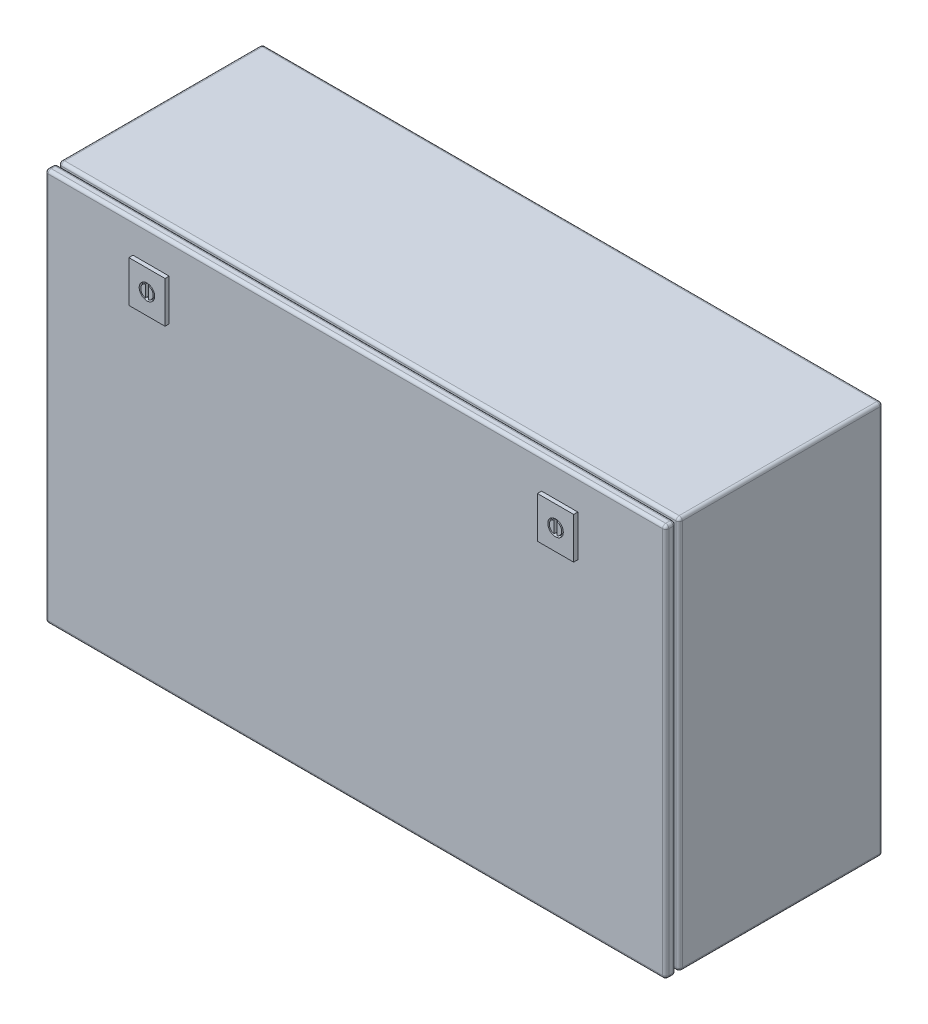
from build123d import *

# Parameters (mm, degrees)
SKETCH1_W           = 600
SKETCH1_H           = 380
BOSS_EXTRUDE1_DEPTH = 210
SKETCH2_W           = 600
SKETCH2_H           = 380
SKETCH2_W_2         = 580
SKETCH2_H_2         = 360
CUT_EXTRUDE3_DEPTH  = 3
FILLET3_R           = 3
SKETCH4_W           = 35
SKETCH4_H           = 40
BOSS_EXTRUDE3_DEPTH = 4
SKETCH5_R           = 7.5
CUT_EXTRUDE6_DEPTH  = 3


with BuildPart() as part:
    # Sketch1 → Boss-Extrude1 (new body)
    with BuildSketch(Plane.XY):
        with Locations((300, 190)):
            Rectangle(SKETCH1_W, SKETCH1_H)
    extrude(amount=BOSS_EXTRUDE1_DEPTH)

    # Sketch2 → Cut-Extrude3 (cut)
    with BuildSketch(Plane.XY.offset(200)):
        with Locations((300, 190)):
            Rectangle(SKETCH2_W, SKETCH2_H)
        with Locations((300, 190)):
            Rectangle(SKETCH2_W_2, SKETCH2_H_2, mode=Mode.SUBTRACT)
    extrude(amount=-CUT_EXTRUDE3_DEPTH, mode=Mode.SUBTRACT)

    # Fillet3
    fillet3_edges = [part.edges().sort_by_distance(p)[0] for p in [
        (600, 190, 210),
        (0, 380, 98.5),
        (600, 380, 98.5),
        (600, 0, 98.5),
        (300, 380, 210),
        (0, 0, 98.5),
        (0, 190, 197),
        (300, 380, 197),
        (600, 190, 197),
        (300, 0, 197),
        (0, 190, 200),
        (300, 0, 200),
        (600, 190, 200),
        (300, 380, 200),
        (0, 190, 210),
        (300, 380, 0),
        (600, 190, 0),
        (300, 0, 0),
        (0, 190, 0),
        (0, 380, 205),
        (600, 380, 205),
        (600, 0, 205),
        (0, 0, 205),
        (300, 0, 210),
    ]]
    fillet(fillet3_edges, radius=FILLET3_R)

    # Sketch4 → Boss-Extrude3 (add)
    with BuildSketch(Plane.XY.offset(210)):
        with Locations((102.5, 330)):
            Rectangle(SKETCH4_W, SKETCH4_H)
        with Locations((497.5, 330)):
            Rectangle(SKETCH4_W, SKETCH4_H)
    extrude(amount=BOSS_EXTRUDE3_DEPTH)

    # Sketch5 → Cut-Extrude6 (cut)
    with BuildSketch(Plane.XY.offset(214)):
        with Locations((102.5, 330)):
            Circle(SKETCH5_R)
        with BuildLine():
            ThreePointArc((101, 335.809475019), (96.5, 330), (101, 324.190524981))
            Line((101, 324.190524981), (101, 335.809475019))
        make_face(mode=Mode.SUBTRACT)
        with BuildLine():
            ThreePointArc((104, 324.190524981), (108.5, 330), (104, 335.809475019))
            Line((104, 335.809475019), (104, 324.190524981))
        make_face(mode=Mode.SUBTRACT)
        with Locations((497.5, 330)):
            Circle(SKETCH5_R)
        with BuildLine():
            Line((496, 335.809475019), (496, 324.190524981))
            ThreePointArc((496, 324.190524981), (491.5, 330), (496, 335.809475019))
        make_face(mode=Mode.SUBTRACT)
        with BuildLine():
            Line((499, 335.809475019), (499, 324.190524981))
            ThreePointArc((499, 324.190524981), (503.5, 330), (499, 335.809475019))
        make_face(mode=Mode.SUBTRACT)
    extrude(amount=-CUT_EXTRUDE6_DEPTH, mode=Mode.SUBTRACT)


solid = part.part
